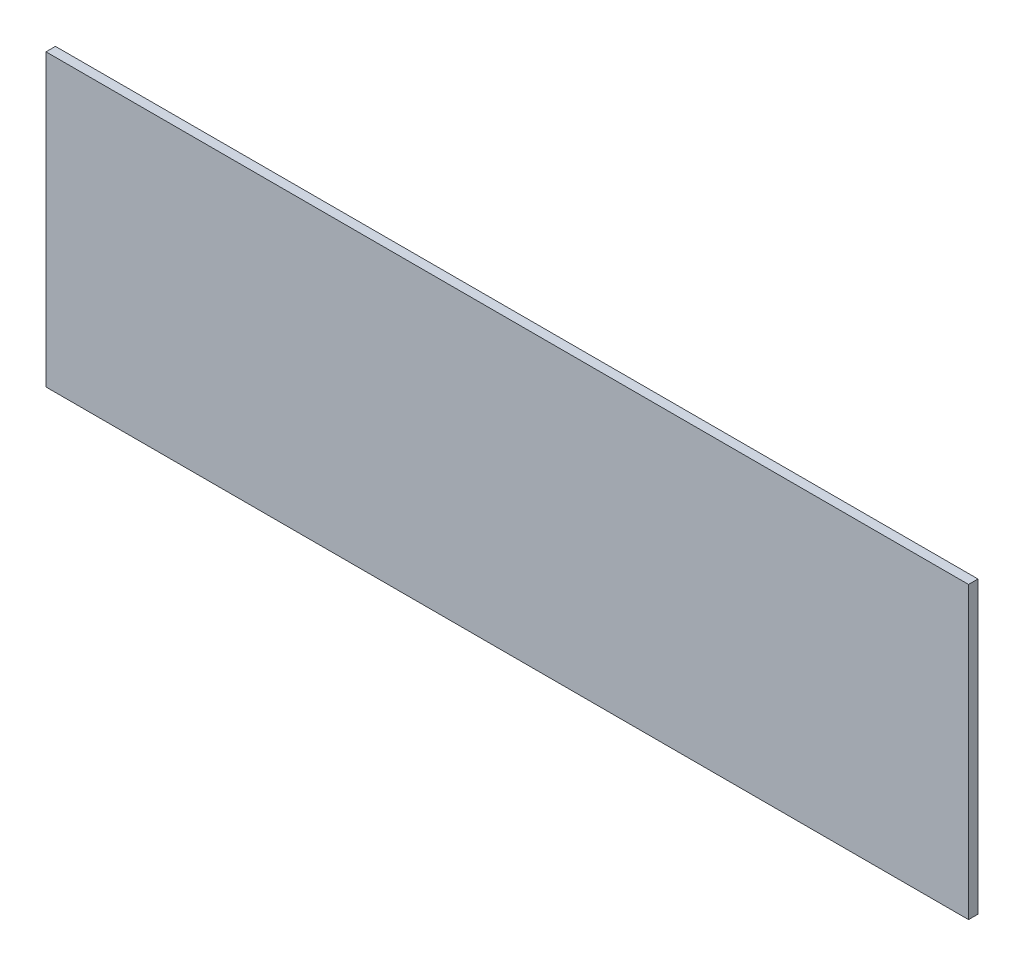
from build123d import *

# Parameters (mm, degrees)
SKETCH1_W           = 146.5
SKETCH1_H           = 46.1
BOSS_EXTRUDE1_DEPTH = 1.5


with BuildPart() as part:
    # Sketch1 → Boss-Extrude1 (new body)
    with BuildSketch(Plane.XY):
        Rectangle(SKETCH1_W, SKETCH1_H)
    extrude(amount=BOSS_EXTRUDE1_DEPTH)


solid = part.part
